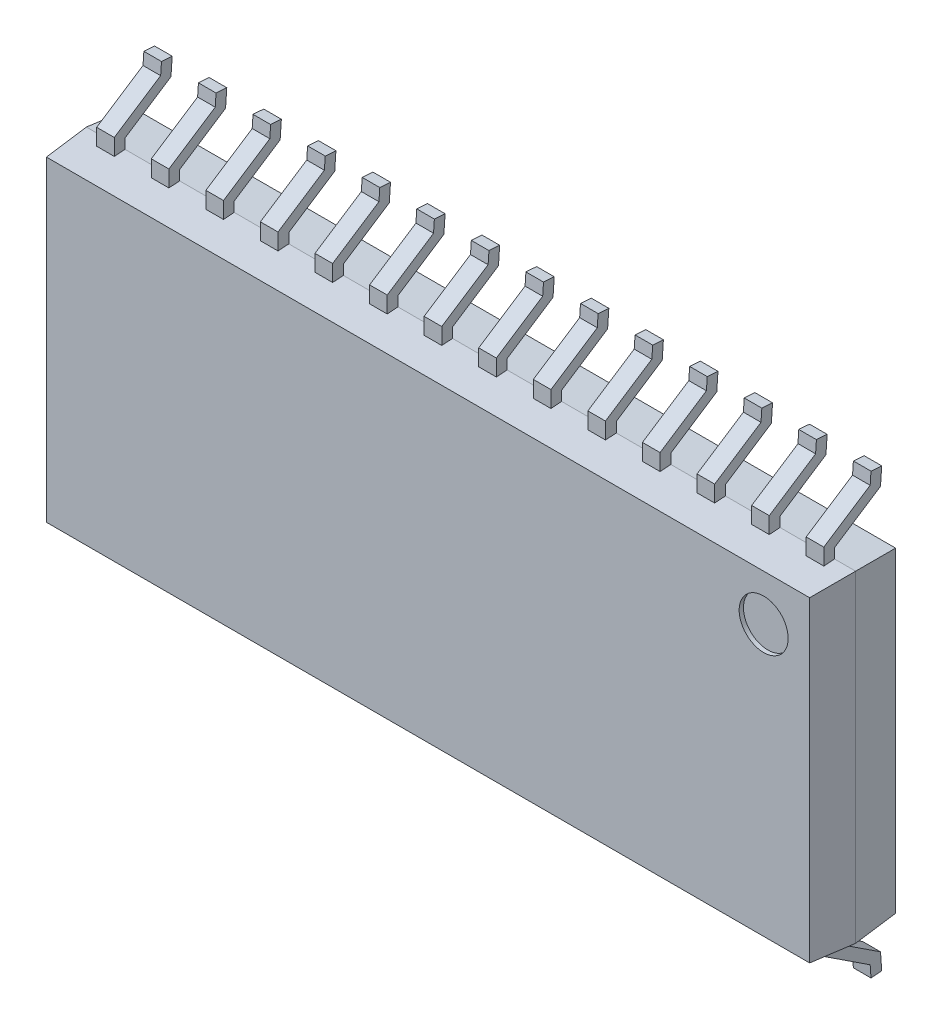
from build123d import *

# Parameters (mm, degrees)
SKETCH1_W             = 17.9
SKETCH1_H             = 7.5
BOSS_EXTRUDE1_DEPTH   = 1
BOSS_EXTRUDE1_TAPER   = 4
SKETCH2_W             = 17.9
SKETCH2_H             = 7.5
BOSS_EXTRUDE2_DEPTH   = 1
BOSS_EXTRUDE2_TAPER   = 4
EXTRUDE_THIN3_DEPTH   = 0.205
LPATTERN1_COUNT       = 14
LPATTERN1_PITCH       = 1.27
MIRROR3_COPY_1_DEPTH  = 0.205
MIRROR3_COPY_2_DEPTH  = 0.205
MIRROR3_COPY_3_DEPTH  = 0.205
MIRROR3_COPY_4_DEPTH  = 0.205
MIRROR3_COPY_5_DEPTH  = 0.205
MIRROR3_COPY_6_DEPTH  = 0.205
MIRROR3_COPY_7_DEPTH  = 0.205
MIRROR3_COPY_8_DEPTH  = 0.205
MIRROR3_COPY_9_DEPTH  = 0.205
MIRROR3_COPY_10_DEPTH = 0.205
MIRROR3_COPY_11_DEPTH = 0.205
MIRROR3_COPY_12_DEPTH = 0.205
MIRROR3_COPY_13_DEPTH = 0.205
SKETCH4_R             = 0.57
CUT_EXTRUDE1_DEPTH    = 0.1


with BuildPart() as part:
    # Sketch1 → Boss-Extrude1 (new body)
    with BuildSketch(Plane.XY):
        with Locations((8.95, 3.75)):
            Rectangle(SKETCH1_W, SKETCH1_H)
    extrude(amount=BOSS_EXTRUDE1_DEPTH, taper=BOSS_EXTRUDE1_TAPER)


with BuildPart() as body_2:
    # Sketch2 → Boss-Extrude2 (new body)
    with BuildSketch(Plane(origin=(0, 0, 0), x_dir=(-1, 0, 0), z_dir=(0, 0, -1))):
        with Locations((-8.95, 3.75)):
            Rectangle(SKETCH2_W, SKETCH2_H)
    extrude(amount=BOSS_EXTRUDE2_DEPTH, taper=BOSS_EXTRUDE2_TAPER)


with BuildPart() as body_3:
    # Sketch3 → Extrude-Thin3 (new body, symmetric)
    with BuildSketch(Plane(origin=(0.695, 0, 0), x_dir=(0, 0, -1), z_dir=(1, 0, 0))):
        Polygon((0, 0.150282381), (0, -0.249717619), (1.068912869, -0.949717619), (1.096883594, -1.349717619), (0.847492581, -1.367156737), (0.828174988, -1.090902281), (-0.25, -0.384836788), (-0.25, 0.150282381), align=None)
    extrude_thin3 = extrude(amount=EXTRUDE_THIN3_DEPTH, both=True)


with BuildPart() as lpattern1_1:
    # LPattern1: Extrude-Thin3 ×14
    with Locations(*[(i * LPATTERN1_PITCH, 0, 0) for i in range(1, LPATTERN1_COUNT)]):
        add(extrude_thin3)


with BuildPart() as part_1:
    add(part.part)

    add(body_2.part)  # Mirror3 merges body 2
    # Mirror3: Extrude-Thin3 across plane
    add(extrude_thin3.mirror(Plane.ZX.offset(3.74)))

    # Mirror3 copy 1 sketch → Mirror3 copy 1 (add, symmetric)
    with BuildSketch(Plane(origin=(1.965, 7.48, 0), x_dir=(0, 0, -1), z_dir=(1, 0, 0))):
        Polygon((0, -0.150282381), (0, 0.249717619), (1.068912869, 0.949717619), (1.096883594, 1.349717619), (0.847492581, 1.367156737), (0.828174988, 1.090902281), (-0.25, 0.384836788), (-0.25, -0.150282381), align=None)
    extrude(amount=MIRROR3_COPY_1_DEPTH, both=True)

    # Mirror3 copy 2 sketch → Mirror3 copy 2 (add, symmetric)
    with BuildSketch(Plane(origin=(3.235, 7.48, 0), x_dir=(0, 0, -1), z_dir=(1, 0, 0))):
        Polygon((0, -0.150282381), (0, 0.249717619), (1.068912869, 0.949717619), (1.096883594, 1.349717619), (0.847492581, 1.367156737), (0.828174988, 1.090902281), (-0.25, 0.384836788), (-0.25, -0.150282381), align=None)
    extrude(amount=MIRROR3_COPY_2_DEPTH, both=True)

    # Mirror3 copy 3 sketch → Mirror3 copy 3 (add, symmetric)
    with BuildSketch(Plane(origin=(4.505, 7.48, 0), x_dir=(0, 0, -1), z_dir=(1, 0, 0))):
        Polygon((0, -0.150282381), (0, 0.249717619), (1.068912869, 0.949717619), (1.096883594, 1.349717619), (0.847492581, 1.367156737), (0.828174988, 1.090902281), (-0.25, 0.384836788), (-0.25, -0.150282381), align=None)
    extrude(amount=MIRROR3_COPY_3_DEPTH, both=True)

    # Mirror3 copy 4 sketch → Mirror3 copy 4 (add, symmetric)
    with BuildSketch(Plane(origin=(5.775, 7.48, 0), x_dir=(0, 0, -1), z_dir=(1, 0, 0))):
        Polygon((0, -0.150282381), (0, 0.249717619), (1.068912869, 0.949717619), (1.096883594, 1.349717619), (0.847492581, 1.367156737), (0.828174988, 1.090902281), (-0.25, 0.384836788), (-0.25, -0.150282381), align=None)
    extrude(amount=MIRROR3_COPY_4_DEPTH, both=True)

    # Mirror3 copy 5 sketch → Mirror3 copy 5 (add, symmetric)
    with BuildSketch(Plane(origin=(7.045, 7.48, 0), x_dir=(0, 0, -1), z_dir=(1, 0, 0))):
        Polygon((0, -0.150282381), (0, 0.249717619), (1.068912869, 0.949717619), (1.096883594, 1.349717619), (0.847492581, 1.367156737), (0.828174988, 1.090902281), (-0.25, 0.384836788), (-0.25, -0.150282381), align=None)
    extrude(amount=MIRROR3_COPY_5_DEPTH, both=True)

    # Mirror3 copy 6 sketch → Mirror3 copy 6 (add, symmetric)
    with BuildSketch(Plane(origin=(8.315, 7.48, 0), x_dir=(0, 0, -1), z_dir=(1, 0, 0))):
        Polygon((0, -0.150282381), (0, 0.249717619), (1.068912869, 0.949717619), (1.096883594, 1.349717619), (0.847492581, 1.367156737), (0.828174988, 1.090902281), (-0.25, 0.384836788), (-0.25, -0.150282381), align=None)
    extrude(amount=MIRROR3_COPY_6_DEPTH, both=True)

    # Mirror3 copy 7 sketch → Mirror3 copy 7 (add, symmetric)
    with BuildSketch(Plane(origin=(9.585, 7.48, 0), x_dir=(0, 0, -1), z_dir=(1, 0, 0))):
        Polygon((0, -0.150282381), (0, 0.249717619), (1.068912869, 0.949717619), (1.096883594, 1.349717619), (0.847492581, 1.367156737), (0.828174988, 1.090902281), (-0.25, 0.384836788), (-0.25, -0.150282381), align=None)
    extrude(amount=MIRROR3_COPY_7_DEPTH, both=True)

    # Mirror3 copy 8 sketch → Mirror3 copy 8 (add, symmetric)
    with BuildSketch(Plane(origin=(10.855, 7.48, 0), x_dir=(0, 0, -1), z_dir=(1, 0, 0))):
        Polygon((0, -0.150282381), (0, 0.249717619), (1.068912869, 0.949717619), (1.096883594, 1.349717619), (0.847492581, 1.367156737), (0.828174988, 1.090902281), (-0.25, 0.384836788), (-0.25, -0.150282381), align=None)
    extrude(amount=MIRROR3_COPY_8_DEPTH, both=True)

    # Mirror3 copy 9 sketch → Mirror3 copy 9 (add, symmetric)
    with BuildSketch(Plane(origin=(12.125, 7.48, 0), x_dir=(0, 0, -1), z_dir=(1, 0, 0))):
        Polygon((0, -0.150282381), (0, 0.249717619), (1.068912869, 0.949717619), (1.096883594, 1.349717619), (0.847492581, 1.367156737), (0.828174988, 1.090902281), (-0.25, 0.384836788), (-0.25, -0.150282381), align=None)
    extrude(amount=MIRROR3_COPY_9_DEPTH, both=True)

    # Mirror3 copy 10 sketch → Mirror3 copy 10 (add, symmetric)
    with BuildSketch(Plane(origin=(13.395, 7.48, 0), x_dir=(0, 0, -1), z_dir=(1, 0, 0))):
        Polygon((0, -0.150282381), (0, 0.249717619), (1.068912869, 0.949717619), (1.096883594, 1.349717619), (0.847492581, 1.367156737), (0.828174988, 1.090902281), (-0.25, 0.384836788), (-0.25, -0.150282381), align=None)
    extrude(amount=MIRROR3_COPY_10_DEPTH, both=True)

    # Mirror3 copy 11 sketch → Mirror3 copy 11 (add, symmetric)
    with BuildSketch(Plane(origin=(14.665, 7.48, 0), x_dir=(0, 0, -1), z_dir=(1, 0, 0))):
        Polygon((0, -0.150282381), (0, 0.249717619), (1.068912869, 0.949717619), (1.096883594, 1.349717619), (0.847492581, 1.367156737), (0.828174988, 1.090902281), (-0.25, 0.384836788), (-0.25, -0.150282381), align=None)
    extrude(amount=MIRROR3_COPY_11_DEPTH, both=True)

    # Mirror3 copy 12 sketch → Mirror3 copy 12 (add, symmetric)
    with BuildSketch(Plane(origin=(15.935, 7.48, 0), x_dir=(0, 0, -1), z_dir=(1, 0, 0))):
        Polygon((0, -0.150282381), (0, 0.249717619), (1.068912869, 0.949717619), (1.096883594, 1.349717619), (0.847492581, 1.367156737), (0.828174988, 1.090902281), (-0.25, 0.384836788), (-0.25, -0.150282381), align=None)
    extrude(amount=MIRROR3_COPY_12_DEPTH, both=True)

    # Mirror3 copy 13 sketch → Mirror3 copy 13 (add, symmetric)
    with BuildSketch(Plane(origin=(17.205, 7.48, 0), x_dir=(0, 0, -1), z_dir=(1, 0, 0))):
        Polygon((0, -0.150282381), (0, 0.249717619), (1.068912869, 0.949717619), (1.096883594, 1.349717619), (0.847492581, 1.367156737), (0.828174988, 1.090902281), (-0.25, 0.384836788), (-0.25, -0.150282381), align=None)
    extrude(amount=MIRROR3_COPY_13_DEPTH, both=True)

    # Sketch4 → Cut-Extrude1 (cut)
    with BuildSketch(Plane.XY.offset(1)):
        with Locations((16.76, 6.36)):
            Circle(SKETCH4_R)
    extrude(amount=-CUT_EXTRUDE1_DEPTH, mode=Mode.SUBTRACT)


solid = Compound([body_3.part, lpattern1_1.part, part_1.part])
